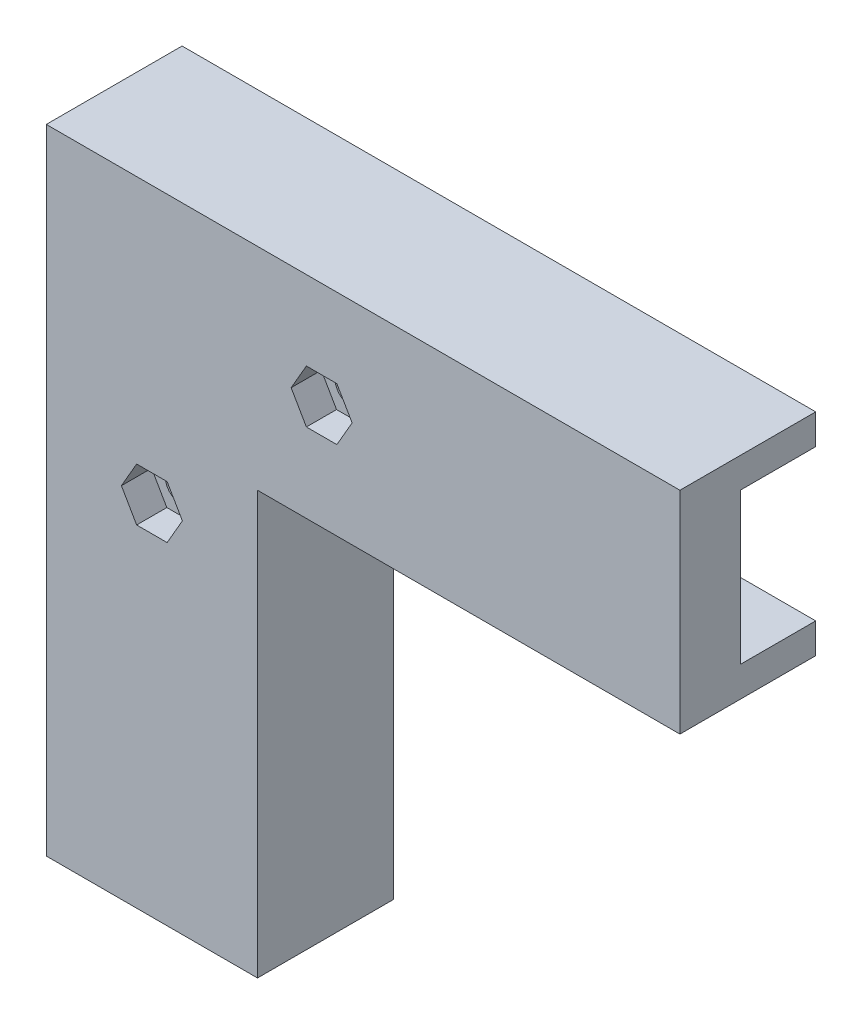
from build123d import *

# Parameters (mm, degrees)
BOSS_EXTRU_1_DEPTH      = 8
ENL_V_MAT_EXTRU_1_DEPTH = 4
ESQUISSE3_R             = 2.25
ENL_V_MAT_EXTRU_2_DEPTH = 5
BOSS_EXTRU_2_DEPTH      = 18
CONG_1_R                = 6


with BuildPart() as part:
    # Esquisse1 → Boss.-Extru.1 (new body)
    with BuildSketch(Plane.XY):
        Polygon((0, 0), (0, 60), (60, 60), (60, 80), (-20, 80), (-20, 0), align=None)
    extrude(amount=BOSS_EXTRU_1_DEPTH)

    # Esquisse2 → Enlèv. mat.-Extru.1 (cut)
    with BuildSketch(Plane.XY.offset(8)):
        Polygon((-14.041451884, 47.5), (-12.020725942, 51), (-7.979274058, 51), (-5.958548116, 47.5), (-7.979274058, 44), (-12.020725942, 44), align=None)
        Polygon((8.458548116, 70), (10.479274058, 73.5), (14.520725942, 73.5), (16.541451884, 70), (14.520725942, 66.5), (10.479274058, 66.5), align=None)
    extrude(amount=-ENL_V_MAT_EXTRU_1_DEPTH, mode=Mode.SUBTRACT)

    # Esquisse3 → Enlèv. mat.-Extru.2 (cut, through all)
    with BuildSketch(Plane.XY.offset(4)):
        with Locations((-10, 47.5)):
            Circle(ESQUISSE3_R)
        with Locations((12.5, 70)):
            Circle(ESQUISSE3_R)
    extrude(amount=-ENL_V_MAT_EXTRU_2_DEPTH, mode=Mode.SUBTRACT)

    # Esquisse4 → Boss.-Extru.2 (add)
    with BuildSketch(Plane.XY.offset(8)):
        Polygon((0, 0), (0, 60), (60, 60), (60, 56), (4, 56), (4, 0), align=None)
        Polygon((60, 80), (60, 84), (-24, 84), (-24, 0), (-20, 0), (-20, 80), align=None)
    extrude(amount=-BOSS_EXTRU_2_DEPTH)

    # Congé1
    cong_1_edges = [part.edges().sort_by_distance(p)[0] for p in [
        (0, 60, -5),
    ]]
    fillet(cong_1_edges, radius=CONG_1_R)


solid = part.part
